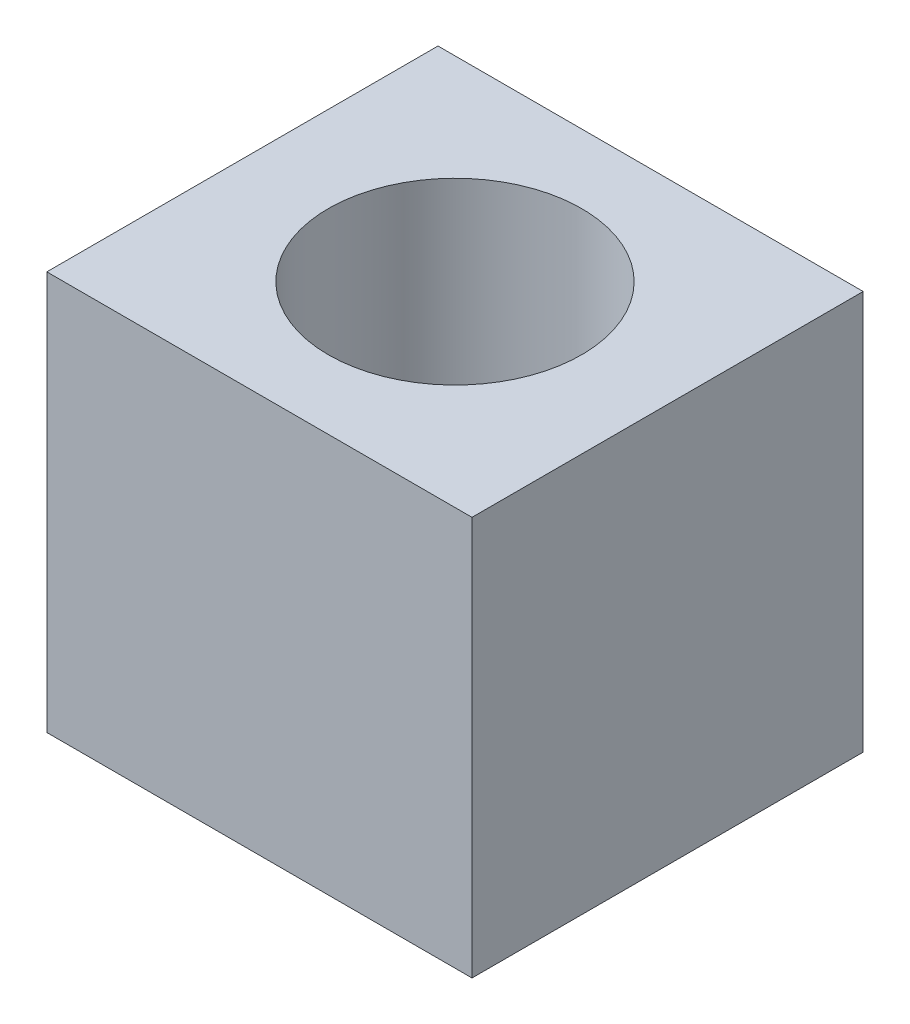
from build123d import *

# Parameters (mm, degrees)
SKETCH1_W           = 21.314329126
SKETCH1_H           = 19.609182796
SKETCH1_R           = 6.35
BOSS_EXTRUDE1_DEPTH = 20


with BuildPart() as part:
    # Sketch1 → Boss-Extrude1 (new body)
    with BuildSketch(Plane(origin=(0, 0, 0), x_dir=(1, 0, 0), z_dir=(0, 1, 0))):
        Rectangle(SKETCH1_W, SKETCH1_H)
        Circle(SKETCH1_R, mode=Mode.SUBTRACT)
    extrude(amount=BOSS_EXTRUDE1_DEPTH)


solid = part.part
